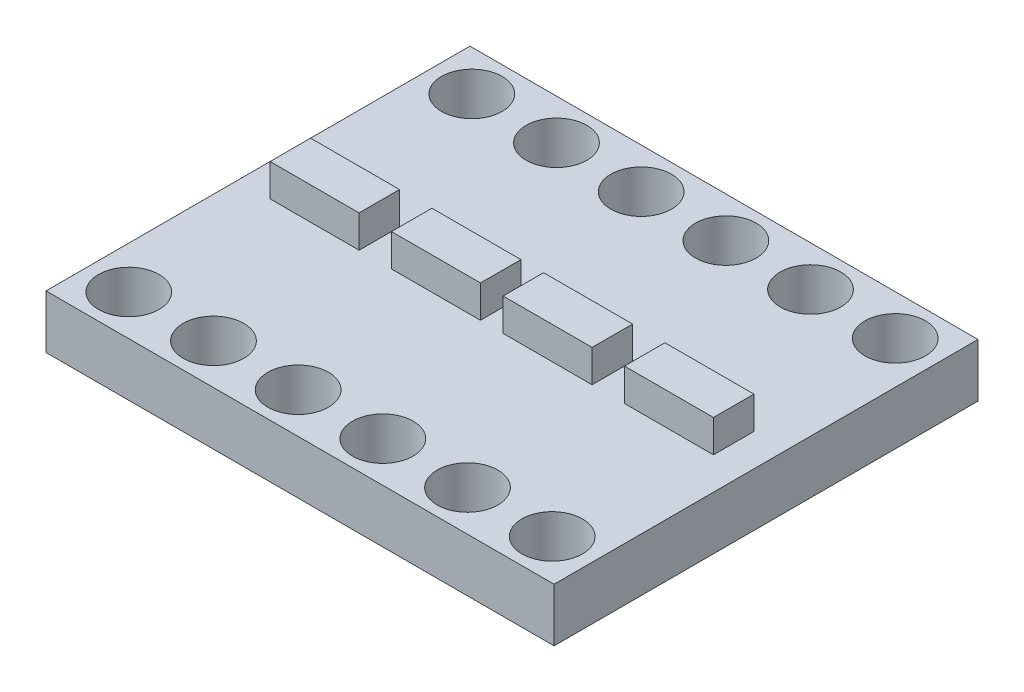
from build123d import *

# Parameters (mm, degrees)
SKETCH1_W           = 15.9512
SKETCH1_H           = 13.3096
BOSS_EXTRUDE1_DEPTH = 1.6764
SKETCH2_W           = 2.794
SKETCH2_H           = 1.27
BOSS_EXTRUDE2_DEPTH = 1.016
SKETCH3_R           = 0.9525
CUT_EXTRUDE1_DEPTH  = 2.6764


with BuildPart() as part:
    # Sketch1 → Boss-Extrude1 (new body)
    with BuildSketch(Plane(origin=(0, 0, 0), x_dir=(1, 0, 0), z_dir=(0, 1, 0))):
        with Locations((7.9756, 6.6548)):
            Rectangle(SKETCH1_W, SKETCH1_H)
    extrude(amount=BOSS_EXTRUDE1_DEPTH)

    # Sketch2 → Boss-Extrude2 (add)
    with BuildSketch(Plane(origin=(0, 1.6764, 0), x_dir=(1, 0, 0), z_dir=(0, 1, 0))):
        with Locations((2.413, 6.6548)):
            Rectangle(SKETCH2_W, SKETCH2_H)
        with Locations((6.223, 6.6548)):
            Rectangle(SKETCH2_W, SKETCH2_H)
        with Locations((9.7282, 6.6548)):
            Rectangle(SKETCH2_W, SKETCH2_H)
        with Locations((13.5382, 6.6548)):
            Rectangle(SKETCH2_W, SKETCH2_H)
    extrude(amount=BOSS_EXTRUDE2_DEPTH)

    # Sketch3 → Cut-Extrude1 (cut, through all)
    with BuildSketch(Plane(origin=(0, 1.6764, 0), x_dir=(1, 0, 0), z_dir=(0, 1, 0))):
        with Locations((1.329266667, 12.0396)):
            Circle(SKETCH3_R)
        with Locations((3.987808467, 12.0396)):
            Circle(SKETCH3_R)
        with Locations((6.646350267, 12.0396)):
            Circle(SKETCH3_R)
        with Locations((9.304892067, 12.0396)):
            Circle(SKETCH3_R)
        with Locations((11.963433867, 12.0396)):
            Circle(SKETCH3_R)
        with Locations((14.621975667, 12.0396)):
            Circle(SKETCH3_R)
        with Locations((14.621975667, 1.27)):
            Circle(SKETCH3_R)
        with Locations((11.963433867, 1.27)):
            Circle(SKETCH3_R)
        with Locations((9.304892067, 1.27)):
            Circle(SKETCH3_R)
        with Locations((6.646350267, 1.27)):
            Circle(SKETCH3_R)
        with Locations((3.987808467, 1.27)):
            Circle(SKETCH3_R)
        with Locations((1.329266667, 1.27)):
            Circle(SKETCH3_R)
    extrude(amount=-CUT_EXTRUDE1_DEPTH, mode=Mode.SUBTRACT)


solid = part.part
